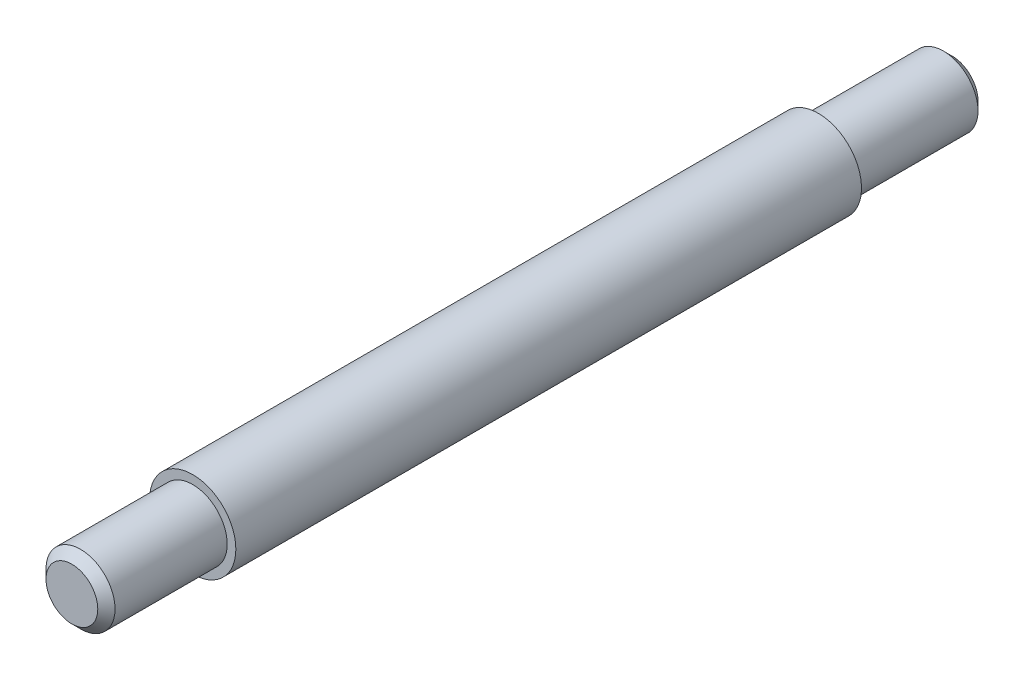
from build123d import *

# Parameters (mm, degrees)
SKIZZE1_R                       = 10
AUFSATZ_LINEAR_AUSTRAGEN1_DEPTH = 204
SKIZZE2_R                       = 10
SKIZZE2_R_2                     = 8
SCHNITT_LINEAR_AUSTRAGEN1_DEPTH = 31
SKIZZE3_R                       = 10
SKIZZE3_R_2                     = 8
SCHNITT_LINEAR_AUSTRAGEN2_DEPTH = 28
FASE1_SIZE                      = 2
FASE2_SIZE                      = 2


with BuildPart() as part:
    # Skizze1 → Aufsatz-Linear austragen1 (new body)
    with BuildSketch(Plane.XY):
        Circle(SKIZZE1_R)
    extrude(amount=AUFSATZ_LINEAR_AUSTRAGEN1_DEPTH)

    # Skizze2 → Schnitt-Linear austragen1 (cut)
    with BuildSketch(Plane(origin=(0, 0, 0), x_dir=(-1, 0, 0), z_dir=(0, 0, -1))):
        Circle(SKIZZE2_R)
        Circle(SKIZZE2_R_2, mode=Mode.SUBTRACT)
    extrude(amount=-SCHNITT_LINEAR_AUSTRAGEN1_DEPTH, mode=Mode.SUBTRACT)

    # Skizze3 → Schnitt-Linear austragen2 (cut)
    with BuildSketch(Plane.XY.offset(204)):
        Circle(SKIZZE3_R)
        Circle(SKIZZE3_R_2, mode=Mode.SUBTRACT)
    extrude(amount=-SCHNITT_LINEAR_AUSTRAGEN2_DEPTH, mode=Mode.SUBTRACT)

    # Fase1
    fase1_edges = [part.edges().sort_by_distance(p)[0] for p in [
        (-8, 0, 204),
    ]]
    chamfer(fase1_edges, length=FASE1_SIZE)

    # Fase2
    fase2_edges = [part.edges().sort_by_distance(p)[0] for p in [
        (8, 0, 0),
    ]]
    chamfer(fase2_edges, length=FASE2_SIZE)


solid = part.part
